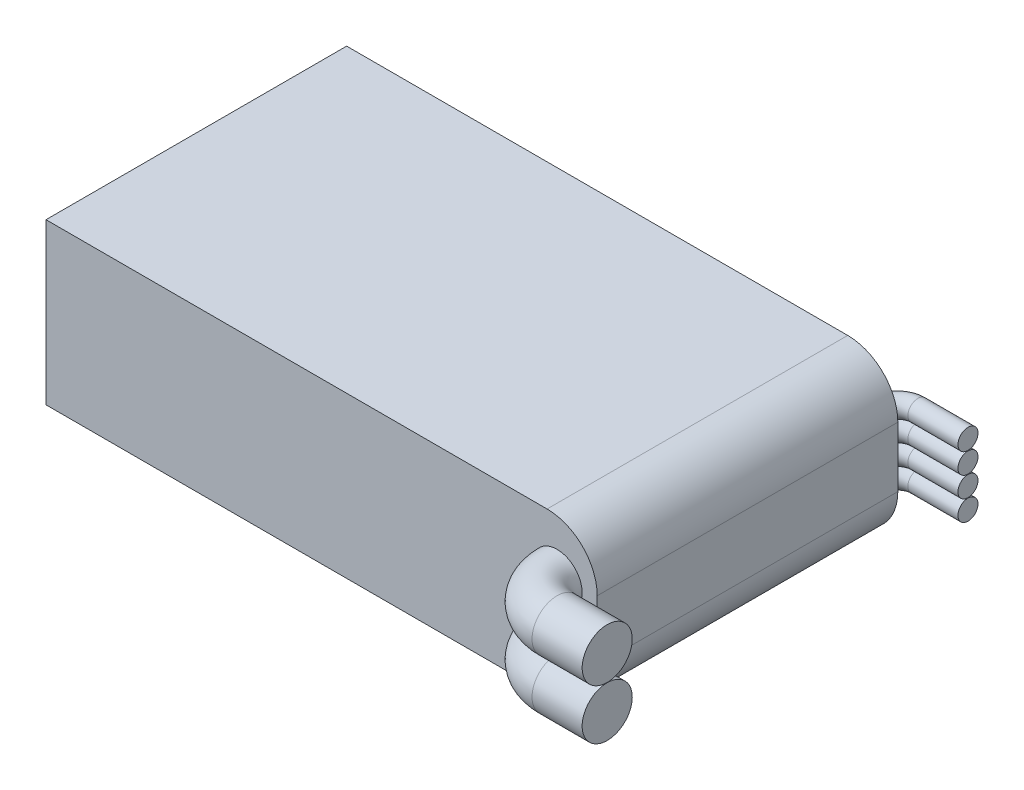
from build123d import *

# Parameters (mm, degrees)
SKETCH1_W           = 55
SKETCH1_H           = 30
BOSS_EXTRUDE1_DEPTH = 16
FILLET1_R           = 5
SKETCH2_R           = 2.5
SKETCH9_R           = 1


with BuildPart() as part:
    # Sketch1 → Boss-Extrude1 (new body)
    with BuildSketch(Plane(origin=(0, 0, 0), x_dir=(1, 0, 0), z_dir=(0, 1, 0))):
        Rectangle(SKETCH1_W, SKETCH1_H)
    extrude(amount=BOSS_EXTRUDE1_DEPTH)

    # Fillet1
    fillet1_edges = [part.edges().sort_by_distance(p)[0] for p in [
        (27.5, 16, 0),
        (27.5, 0, 0),
    ]]
    fillet(fillet1_edges, radius=FILLET1_R)

    # Sweep5: sweep along a path in Sketch7
    with BuildLine(Plane(origin=(0, 0, 0), x_dir=(-1, 0, 0), z_dir=(0, -1, 0))) as sweep5_path:
        Line((-32.5, -19), (-27.5, -19))
        ThreePointArc((-27.5, -19), (-24.671572875, -17.828427125), (-23.5, -15))
    # Sketch2 → Sweep5 (sweep)
    with BuildSketch(Plane.XY.offset(15)):
        with Locations((23.5, 10.51)):
            Circle(SKETCH2_R)
        with Locations((23.5, 5.49)):
            Circle(SKETCH2_R)
    sweep(path=sweep5_path.line)

    # Sweep6: sweep along a path in Sketch10
    with BuildLine(Plane(origin=(0, 0, 0), x_dir=(1, 0, 0), z_dir=(0, 1, 0))) as sweep6_path:
        Line((32.5, 17), (27.5, 17))
        ThreePointArc((27.5, 17), (26.085786438, 16.414213562), (25.5, 15))
    # Sketch9 → Sweep6 (sweep)
    with BuildSketch(Plane(origin=(0, 0, -15), x_dir=(-1, 0, 0), z_dir=(0, 0, -1))):
        with Locations((-25.5, 9.02)):
            Circle(SKETCH9_R)
        with Locations((-25.5, 6.98)):
            Circle(SKETCH9_R)
        with Locations((-25.5, 11.06)):
            Circle(SKETCH9_R)
        with Locations((-25.5, 4.94)):
            Circle(SKETCH9_R)
    sweep(path=sweep6_path.line)


solid = part.part
